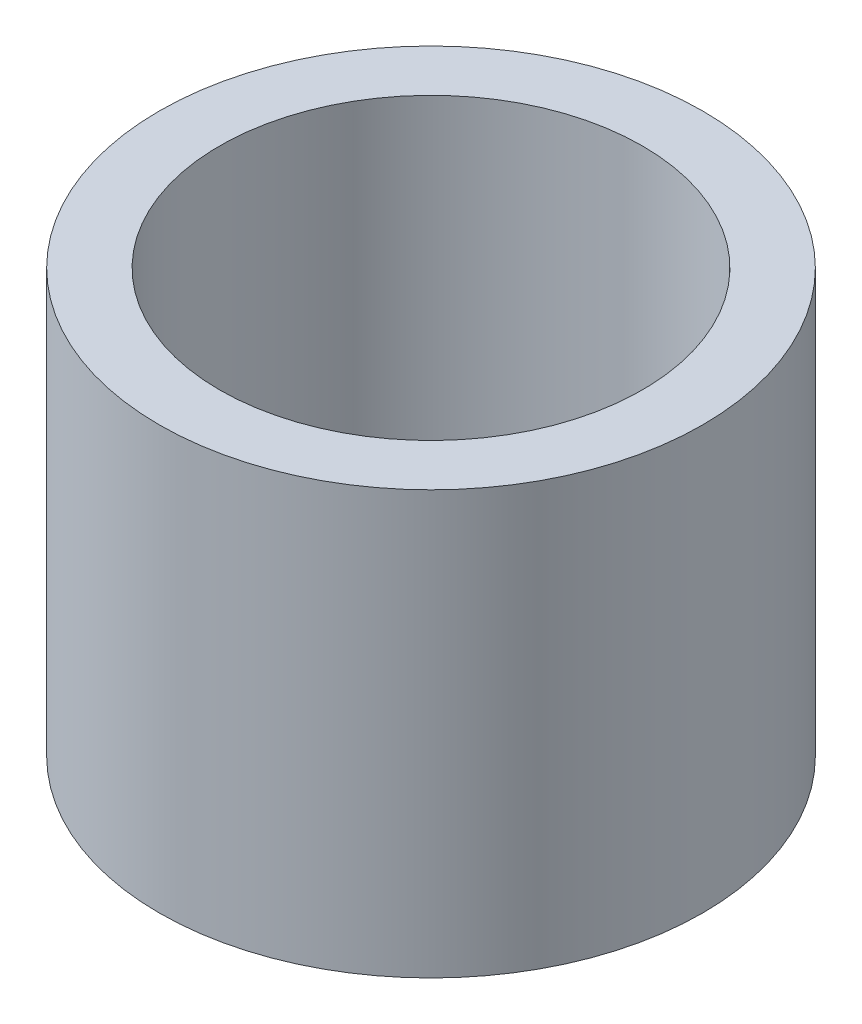
from build123d import *

# Parameters (mm, degrees)
SKETCH_1_R      = 4.5
SKETCH_1_R_2    = 3.5
EXTRUDE_1_DEPTH = 7


with BuildPart() as part:
    # 草图1 → 凸台-拉伸1 (new body)
    with BuildSketch(Plane(origin=(0, 0, 0), x_dir=(1, 0, 0), z_dir=(0, 1, 0))):
        Circle(SKETCH_1_R)
        Circle(SKETCH_1_R_2, mode=Mode.SUBTRACT)
    extrude(amount=EXTRUDE_1_DEPTH)


solid = part.part
